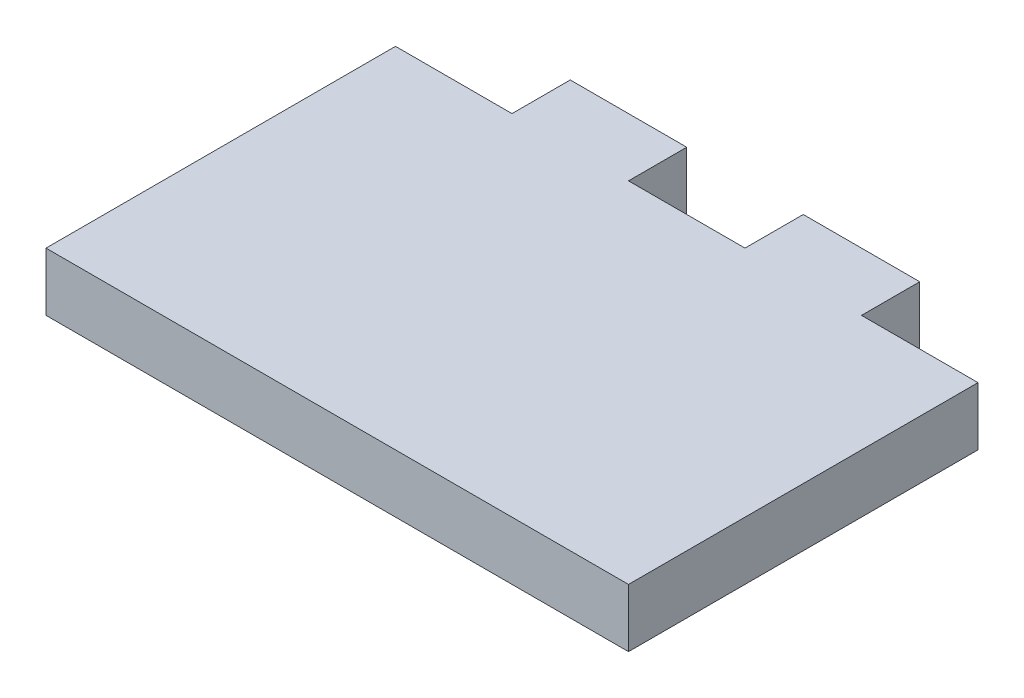
from build123d import *

# Parameters (mm, degrees)
BOSS_EXTRUDE2_DEPTH = 5


with BuildPart() as part:
    # Sketch1 → Boss-Extrude2 (new body)
    with BuildSketch(Plane(origin=(0, 0, 0), x_dir=(1, 0, 0), z_dir=(0, 1, 0))):
        Polygon((-30, 35), (-40, 35), (-40, 30), (-50, 30), (-50, 0), (0, 0), (0, 30), (-10, 30), (-10, 35), (-20, 35), (-20, 30), (-30, 30), align=None)
    extrude(amount=BOSS_EXTRUDE2_DEPTH)


solid = part.part
